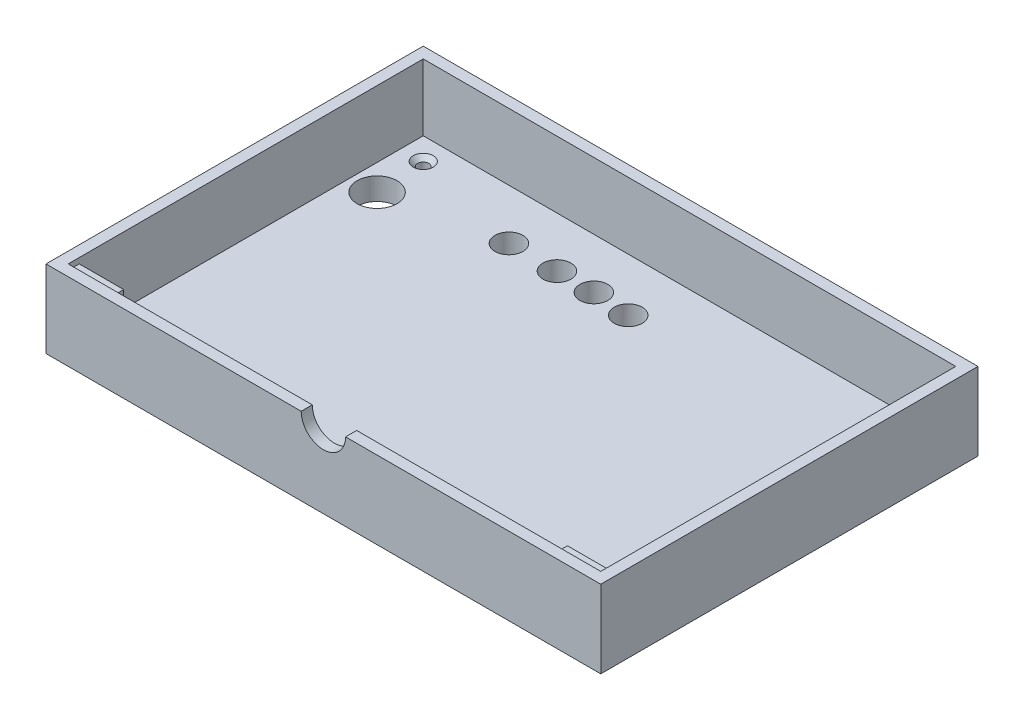
from build123d import *

# Parameters (mm, degrees)
SKETCH1_W             = 304.8
SKETCH1_H             = 203.2
BOSS_EXTRUDE1_DEPTH   = 6.35
SKETCH2_W             = 317.5
SKETCH2_H             = 215.9
BOSS_EXTRUDE2_DEPTH   = 6.35
SKETCH3_R             = 3.175
CUT_EXTRUDE1_DEPTH    = 12.7
CHAMFER1_SIZE         = 2.54
SKETCH6_W             = 317.5
SKETCH6_H             = 215.9
SKETCH6_W_2           = 304.8
SKETCH6_H_2           = 203.2
BOSS_EXTRUDE3_DEPTH   = 38.1
SKETCH7_W             = 25.4
SKETCH7_H             = 6.35
BOSS_EXTRUDE4_DEPTH   = 6.35
BOSS_EXTRUDE4_2_DEPTH = 6.35
CUT_EXTRUDE4_DEPTH    = 6.35
SKETCH4_R             = 11.43
SKETCH4_R_2           = 8
CUT_EXTRUDE2_DEPTH    = 12.7


with BuildPart() as part:
    # Sketch1 → Boss-Extrude1 (new body)
    with BuildSketch(Plane(origin=(0, 0, 0), x_dir=(1, 0, 0), z_dir=(0, 1, 0))):
        Rectangle(SKETCH1_W, SKETCH1_H)
    extrude(amount=BOSS_EXTRUDE1_DEPTH)

    # Sketch2 → Boss-Extrude2 (add)
    with BuildSketch(Plane(origin=(0, 6.35, 0), x_dir=(1, 0, 0), z_dir=(0, 1, 0))):
        Rectangle(SKETCH2_W, SKETCH2_H)
    extrude(amount=BOSS_EXTRUDE2_DEPTH)

    # Sketch3 → Cut-Extrude1 (cut)
    with BuildSketch(Plane(origin=(0, 12.7, 0), x_dir=(1, 0, 0), z_dir=(0, 1, 0))):
        with Locations((-139.7, 88.9)):
            Circle(SKETCH3_R)
        with Locations((139.7, 88.9)):
            Circle(SKETCH3_R)
        with Locations((139.7, -88.9)):
            Circle(SKETCH3_R)
        with Locations((-139.7, -88.9)):
            Circle(SKETCH3_R)
    extrude(amount=-CUT_EXTRUDE1_DEPTH, mode=Mode.SUBTRACT)

    # Chamfer1
    chamfer1_edges = [part.edges().sort_by_distance(p)[0] for p in [
        (-142.875, 12.7, -88.9),
        (-142.875, 12.7, 88.9),
        (136.525, 12.7, 88.9),
        (136.525, 12.7, -88.9),
    ]]
    chamfer(chamfer1_edges, length=CHAMFER1_SIZE)

    # Sketch6 → Boss-Extrude3 (add)
    with BuildSketch(Plane(origin=(0, 12.7, 0), x_dir=(1, 0, 0), z_dir=(0, 1, 0))):
        Rectangle(SKETCH6_W, SKETCH6_H)
        Rectangle(SKETCH6_W_2, SKETCH6_H_2, mode=Mode.SUBTRACT)
    extrude(amount=BOSS_EXTRUDE3_DEPTH)

    # Sketch8 → Cut-Extrude4 (cut)
    with BuildSketch(Plane.XY.offset(107.95)):
        with BuildLine():
            Line((-12.7, 50.8), (12.7, 50.8))
            ThreePointArc((12.7, 50.8), (0, 38.1), (-12.7, 50.8))
        make_face()
    extrude(amount=-CUT_EXTRUDE4_DEPTH, mode=Mode.SUBTRACT)

    # Sketch4 → Cut-Extrude2 (cut)
    with BuildSketch(Plane(origin=(0, 12.7, 0), x_dir=(1, 0, 0), z_dir=(0, 1, 0))):
        with Locations((-137.6617313, 60.452979471)):
            Circle(SKETCH4_R)
        with Locations((-74.550951205, 72.792379988)):
            Circle(SKETCH4_R_2)
        with Locations((-47.067953057, 72.792379988)):
            Circle(SKETCH4_R_2)
        with Locations((-25.949935803, 72.792379988)):
            Circle(SKETCH4_R_2)
        with Locations((-4.796640674, 71.307645451)):
            Circle(SKETCH4_R_2)
    extrude(amount=-CUT_EXTRUDE2_DEPTH, mode=Mode.SUBTRACT)


with BuildPart() as body_2:
    # Sketch7 → Boss-Extrude4 (new body)
    with BuildSketch(Plane(origin=(0, 0, 101.6), x_dir=(-1, 0, 0), z_dir=(0, 0, -1))):
        with Locations((-139.7, 44.45)):
            Rectangle(SKETCH7_W, SKETCH7_H)
    extrude(amount=BOSS_EXTRUDE4_DEPTH)


with BuildPart() as body_3:
    # Sketch7 → Boss-Extrude4 2 (new body)
    with BuildSketch(Plane(origin=(0, 0, 101.6), x_dir=(-1, 0, 0), z_dir=(0, 0, -1))):
        with Locations((139.7, 44.45)):
            Rectangle(SKETCH7_W, SKETCH7_H)
    extrude(amount=BOSS_EXTRUDE4_2_DEPTH)


solid = Compound([part.part, body_2.part, body_3.part])
